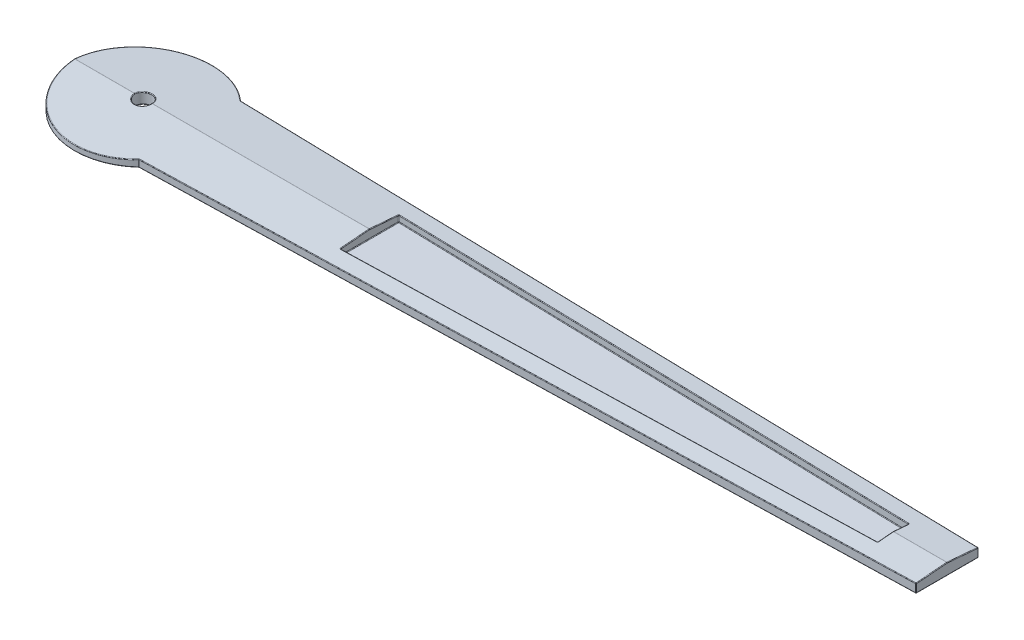
from build123d import *

# Parameters (mm, degrees)
SKETCH2_R           = 0.15
BOSS_EXTRUDE1_DEPTH = 0.2
BOSS_EXTRUDE2_DEPTH = 0.05
CUT_EXTRUDE1_DEPTH  = 20.025
FILLET1_R           = 0.01


with BuildPart() as part:
    # Sketch2 → Boss-Extrude1 (new body)
    with BuildSketch(Plane(origin=(0, 0, 0), x_dir=(1, 0, 0), z_dir=(0, 1, 0))):
        with BuildLine():
            Line((14.204402425, 0), (14.204402425, -0.55))
            Line((14.204402425, -0.55), (0.820579444, -0.896874885))
            ThreePointArc((0.820579444, -0.896874885), (-1.215621316, 0), (0.820579444, 0.896874885))
            Line((0.820579444, 0.896874885), (14.204402425, 0.55))
            Line((14.204402425, 0.55), (14.204402425, 0))
        make_face()
        with Locations(Location((0, 0, 0), (0, 0, 270))):
            Circle(SKETCH2_R, mode=Mode.SUBTRACT)
        Polygon((13.25, 0.27463496), (4, 0.514371595), (4, -0.514371595), (13.25, -0.27463496), align=None, mode=Mode.SUBTRACT)
    extrude(amount=BOSS_EXTRUDE1_DEPTH)

    # Sketch4 → Boss-Extrude2 (add)
    with BuildSketch(Plane.XZ):
        Polygon((4, -0.514371595), (4, 0.514371595), (13.25, 0.27463496), (13.25, -0.27463496), align=None)
    extrude(amount=-BOSS_EXTRUDE2_DEPTH)

    # Sketch5 → Cut-Extrude1 (cut, symmetric)
    with BuildSketch(Plane(origin=(0, 0, 0), x_dir=(0, 0, -1), z_dir=(1, 0, 0))):
        Polygon((-1.215621316, 0.1), (0, 0.2), (1.215621316, 0.1), (1.488581313, 0.465890593), (-1.53428184, 0.564355191), align=None)
    extrude(amount=CUT_EXTRUDE1_DEPTH, both=True, mode=Mode.SUBTRACT)

    # Fillet1
    fillet1_edges = [part.edges().sort_by_distance(p)[0] for p in [
        (0, 0, -0.15),
        (8.625, 0.05, -0.394503277),
        (4, 0.05, 0),
        (8.625, 0.05, 0.394503277),
        (13.25, 0.05, 0),
        (4, 0.103843264, 0.514371595),
        (13.25, 0.113703926, 0.27463496),
        (8.625, 0.16754719, 0.394503277),
        (4, 0.103843264, -0.514371595),
        (4, 0.178843264, -0.257185798),
        (13.25, 0.113703926, -0.27463496),
        (7.512490934, 0, -0.723437443),
        (0.820579444, 0.063110433, -0.896874885),
        (14.204402425, 0.077377823, -0.55),
        (14.204402425, 0.077377823, 0.55),
        (14.204402425, 0, 0),
        (0.820579444, 0.063110433, 0.896874885),
        (-0.860298422, 0.129348959, -0.858849118),
        (7.512490934, 0.140488256, -0.723437443),
        (14.204402425, 0.177377823, -0.275),
        (0, 0.187660631, -0.15),
        (8.625, 0.16754719, -0.394503277),
        (13.25, 0.188703926, -0.13731748),
        (-0.860298422, 0.129348959, 0.858849118),
        (-0.682810658, 0.2, 0),
        (2.075, 0.2, 0),
        (13.727201212, 0.2, 0),
        (14.204402425, 0.177377823, 0.275),
        (7.512490934, 0.140488256, 0.723437443),
        (0.106155397, 0.191282107, 0.105976562),
        (13.25, 0.188703926, 0.13731748),
        (4, 0.178843264, 0.257185798),
        (7.512490934, 0, 0.723437443),
        (-1.215621316, 0, 0),
    ]]
    fillet(fillet1_edges, radius=FILLET1_R)


solid = part.part
